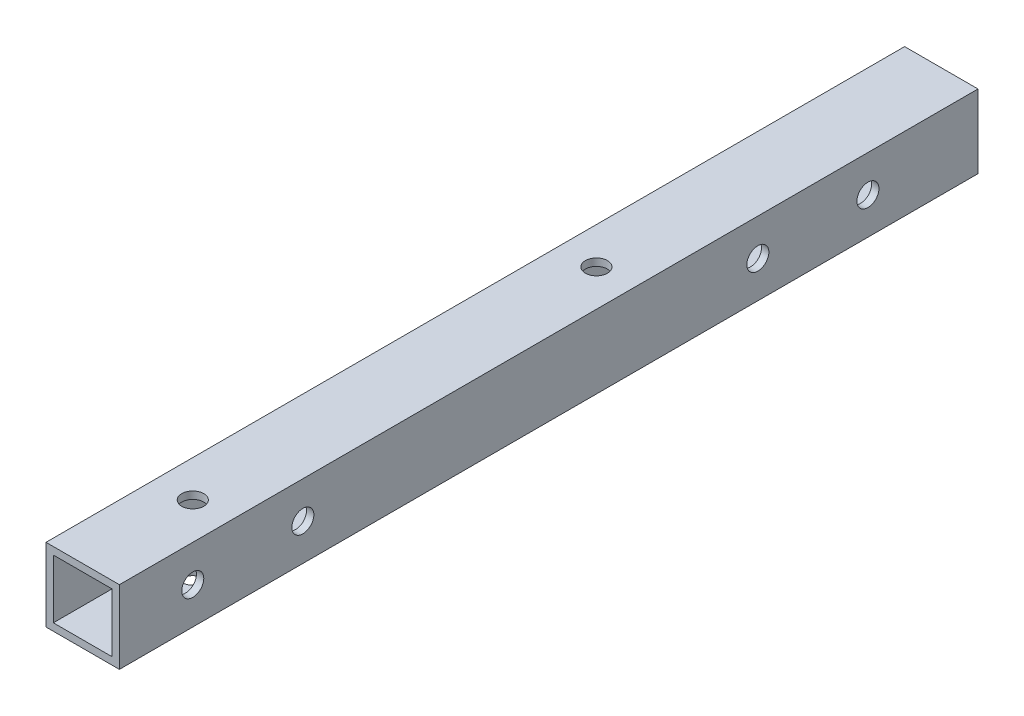
from build123d import *

# Parameters (mm, degrees)
SKETCH_1_W          = 10
SKETCH_1_H          = 10
SKETCH_1_W_2        = 8
SKETCH_1_H_2        = 8
EXTRUDE_1_DEPTH     = 117
SKETCH_2_R          = 1.5
CUT_EXTRUDE_1_DEPTH = 11
SKETCH_3_R          = 1.5
CUT_EXTRUDE_2_DEPTH = 10


with BuildPart() as part:
    # 草图1 → 拉伸-薄壁1 (new body)
    with BuildSketch(Plane.XY):
        Rectangle(SKETCH_1_W, SKETCH_1_H)
        Rectangle(SKETCH_1_W_2, SKETCH_1_H_2, mode=Mode.SUBTRACT)
    extrude(amount=EXTRUDE_1_DEPTH)

    # 草图2 → 切除-拉伸1 (cut, through all)
    with BuildSketch(Plane(origin=(5, 0, 0), x_dir=(0, 0, -1), z_dir=(1, 0, 0))):
        with Locations((-15, 0)):
            Circle(SKETCH_2_R)
        with Locations((-30, 0)):
            Circle(SKETCH_2_R)
        with Locations((-107, 0)):
            Circle(SKETCH_2_R)
        with Locations((-92, 0)):
            Circle(SKETCH_2_R)
    extrude(amount=-CUT_EXTRUDE_1_DEPTH, mode=Mode.SUBTRACT)

    # 草图3 → 切除-拉伸2 (cut)
    with BuildSketch(Plane.XZ.offset(5)):
        with Locations((0, 102)):
            Circle(SKETCH_3_R)
        with Locations((0, 47)):
            Circle(SKETCH_3_R)
    extrude(amount=-CUT_EXTRUDE_2_DEPTH, mode=Mode.SUBTRACT)


solid = part.part
